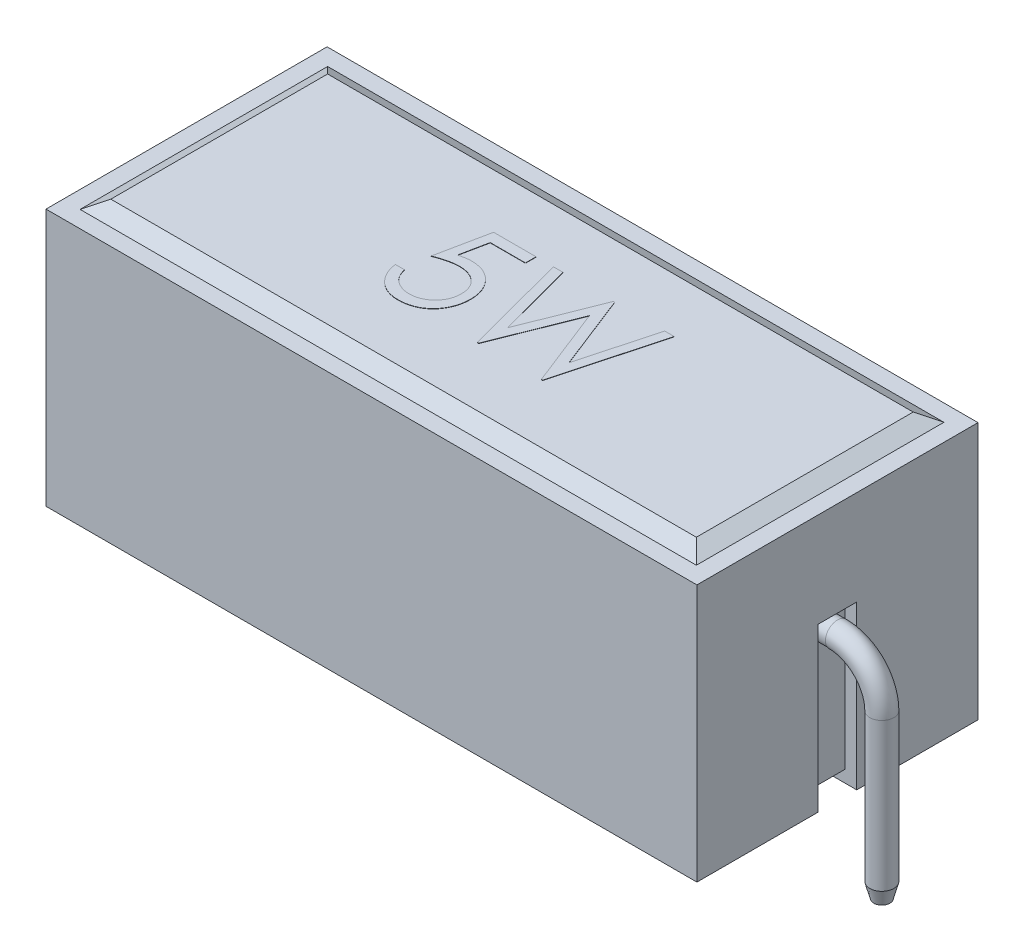
from build123d import *

# Parameters (mm, degrees)
SKETCH1_W            = 22
SKETCH1_H            = 9.5
BOSS_EXTRUDE1_DEPTH  = 8.7
SKETCH2_W            = 20.829563068
SKETCH2_H            = 8.366808904
BOSS_EXTRUDE2_DEPTH  = 0.3
BOSS_EXTRUDE2_TAPER  = 60
CUT_EXTRUDE1_DEPTH   = 0.4
CUT_EXTRUDE2_DEPTH   = 0.4
SKETCH5_W            = 1.3
SKETCH5_H            = 5.5
CUT_EXTRUDE4_DEPTH   = 0.4
SKETCH6_R            = 0.4
BOSS_EXTRUDE3_DEPTH  = 0.4
SKETCH7_R            = 0.4
BOSS_EXTRUDE4_DEPTH  = 0.4
SKETCH11_R           = 0.407100773
SKETCH14_R           = 0.407100773
BOSS_EXTRUDE6_DEPTH  = 5
SKETCH15_R           = 0.4
SKETCH17_R           = 0.4
BOSS_EXTRUDE7_DEPTH  = 5
SKETCH18_R           = 0.407100773
BOSS_EXTRUDE8_DEPTH  = 0.5
BOSS_EXTRUDE8_TAPER  = 15
SKETCH19_R           = 0.4
BOSS_EXTRUDE9_DEPTH  = 0.5
BOSS_EXTRUDE9_TAPER  = 15
BOSS_EXTRUDE10_DEPTH = 0.01


with BuildPart() as part:
    # Sketch1 → Boss-Extrude1 (new body)
    with BuildSketch(Plane(origin=(0, 0, 0), x_dir=(1, 0, 0), z_dir=(0, 1, 0))):
        Rectangle(SKETCH1_W, SKETCH1_H)
    extrude(amount=BOSS_EXTRUDE1_DEPTH)

    # Sketch3 → Cut-Extrude1 (cut)
    with BuildSketch(Plane(origin=(0, 0, 0), x_dir=(-1, 0, 0), z_dir=(0, -1, 0))):
        Polygon((11, -0.65), (9.9, -0.65), (8.5, -2.8), (-8.5, -2.8), (-9.9, -0.65), (-11, -0.65), (-11, 0.65), (-9.9, 0.65), (-8.5, 2.8), (8.5, 2.8), (9.9, 0.65), (11, 0.65), align=None)
    extrude(amount=-CUT_EXTRUDE1_DEPTH, mode=Mode.SUBTRACT)

    # Sketch4 → Cut-Extrude2 (cut)
    with BuildSketch(Plane(origin=(11, 0, 0), x_dir=(0, 0, -1), z_dir=(1, 0, 0))):
        Polygon((0, 0), (0.65, 0), (0.65, 5.5), (-0.65, 5.5), (-0.65, 0), align=None)
    extrude(amount=-CUT_EXTRUDE2_DEPTH, mode=Mode.SUBTRACT)

    # Sketch5 → Cut-Extrude4 (cut)
    with BuildSketch(Plane.ZY.offset(11)):
        with Locations((0, 2.75)):
            Rectangle(SKETCH5_W, SKETCH5_H)
    extrude(amount=-CUT_EXTRUDE4_DEPTH, mode=Mode.SUBTRACT)

    # Sketch6 → Boss-Extrude3 (add)
    with BuildSketch(Plane(origin=(10.6, 0, 0), x_dir=(0, 0, -1), z_dir=(1, 0, 0))):
        with Locations((0, 4.9)):
            Circle(SKETCH6_R)
    extrude(amount=BOSS_EXTRUDE3_DEPTH)

    # Sketch7 → Boss-Extrude4 (add)
    with BuildSketch(Plane.ZY.offset(10.6)):
        with Locations((0, 4.9)):
            Circle(SKETCH7_R)
    extrude(amount=BOSS_EXTRUDE4_DEPTH)

    # Sweep1: sweep along a path in Sketch13
    with BuildLine(Plane.XY) as sweep1_path:
        ThreePointArc((11, 4.892899227), (12.060644746, 4.453574824), (12.499999999, 3.392942857))
    # Sketch11 → Sweep1 (sweep)
    with BuildSketch(Plane(origin=(11, 0, 0), x_dir=(0, 0, -1), z_dir=(1, 0, 0))):
        with Locations((0, 4.892899227)):
            Circle(SKETCH11_R)
    sweep(path=sweep1_path.line)

    # Sketch14 → Boss-Extrude6 (add)
    with BuildSketch(Plane(origin=(-9.868e-05, 3.392579268, 0), x_dir=(1, 2.9087e-05, 0), z_dir=(2.9087e-05, -1, 0))):
        with Locations((12.500098684, 0)):
            Circle(SKETCH14_R)
    extrude(amount=BOSS_EXTRUDE6_DEPTH)

    # Sweep2: sweep along a path in Sketch16
    with BuildLine(Plane.XY) as sweep2_path:
        ThreePointArc((-12.499999995, 3.399877229), (-12.060703577, 4.460616765), (-11, 4.9))
    # Sketch15 → Sweep2 (sweep)
    with BuildSketch(Plane.ZY.offset(11)):
        with Locations((0, 4.9)):
            Circle(SKETCH15_R)
    sweep(path=sweep2_path.line)

    # Sketch17 → Boss-Extrude7 (add)
    with BuildSketch(Plane(origin=(-0.000278355, 3.400900299, 0), x_dir=(0.999999997, 8.1847e-05, 0), z_dir=(8.1847e-05, -0.999999997, 0))):
        with Locations((-12.499721682, 0)):
            Circle(SKETCH17_R)
    extrude(amount=BOSS_EXTRUDE7_DEPTH)

    # Sketch18 → Boss-Extrude8 (add)
    with BuildSketch(Plane(origin=(4.6755e-05, -1.60742073, 0), x_dir=(1, 2.9087e-05, 0), z_dir=(2.9087e-05, -1, 0))):
        with Locations((12.500098684, 0)):
            Circle(SKETCH18_R)
    extrude(amount=BOSS_EXTRUDE8_DEPTH, taper=BOSS_EXTRUDE8_TAPER)

    # Sketch19 → Boss-Extrude9 (add)
    with BuildSketch(Plane(origin=(0.000130882, -1.599099684, 0), x_dir=(0.999999997, 8.1847e-05, 0), z_dir=(8.1847e-05, -0.999999997, 0))):
        with Locations((-12.499721682, 0)):
            Circle(SKETCH19_R)
    extrude(amount=BOSS_EXTRUDE9_DEPTH, taper=BOSS_EXTRUDE9_TAPER)


with BuildPart() as body_2:
    # Sketch2 → Boss-Extrude2 (new body)
    with BuildSketch(Plane(origin=(0, 8.7, 0), x_dir=(1, 0, 0), z_dir=(0, 1, 0))):
        Rectangle(SKETCH2_W, SKETCH2_H)
    extrude(amount=BOSS_EXTRUDE2_DEPTH, taper=BOSS_EXTRUDE2_TAPER)

    # Sketch20 → Boss-Extrude10 (add)
    with BuildSketch(Plane(origin=(0, 9, 0), x_dir=(1, 0, 0), z_dir=(0, 1, 0))):
        with BuildLine():
            Line((-1.01173536, 1.825977974), (-1.01173536, 1.467003615))
            Line((-1.01173536, 1.467003615), (-2.202240168, 1.467003615))
            Line((-2.202240168, 1.467003615), (-2.390841931, 0.546430699))
            add(Edge.make_bspline(
                [(-2.390841931, 0.546430699), (-2.353786056, 0.556660971), (-2.281996161, 0.576480504), (-2.1760363, 0.598486275), (-2.075444096, 0.611751719), (-2.010168726, 0.613563029), (-1.978582315, 0.614439513)],
                knots=[0, 0, 0, 0, 0.000115302, 0.000223379, 0.000324431, 0.000419176, 0.000419176, 0.000419176, 0.000419176], degree=3))
            add(Edge.make_bspline(
                [(-1.978582315, 0.614439513), (-1.939498576, 0.613593577), (-1.862650178, 0.611930256), (-1.750211231, 0.595958407), (-1.642878338, 0.570818492), (-1.540875968, 0.53569797), (-1.444015417, 0.490788237), (-1.353187856, 0.434688297), (-1.267029943, 0.369154966), (-1.187087349, 0.293809954), (-1.114563041, 0.210888337), (-1.050797051, 0.121730466), (-0.996634461, 0.027202804), (-0.953073706, -0.073597805), (-0.918289372, -0.179556958), (-0.895137377, -0.291789541), (-0.879720668, -0.409237661), (-0.877998282, -0.489542231), (-0.877119976, -0.530492378)],
                knots=[0, 0, 0, 0, 0.00011719, 0.000230425, 0.000339944, 0.000447481, 0.000553499, 0.000659556, 0.000767111, 0.000877722, 0.000988528, 0.001097091, 0.001206056, 0.001314692, 0.001425996, 0.001539995, 0.001658004, 0.001780798, 0.001780798, 0.001780798, 0.001780798], degree=3))
            add(Edge.make_bspline(
                [(-0.877119976, -0.530492378), (-0.877785051, -0.559014599), (-0.879106214, -0.615673586), (-0.885824801, -0.699817787), (-0.898760517, -0.78218062), (-0.916128241, -0.862773012), (-0.938670659, -0.941442384), (-0.965959713, -1.018413912), (-0.999355741, -1.093208519), (-1.035987116, -1.166533914), (-1.077233594, -1.236732421), (-1.123012101, -1.302381407), (-1.171377593, -1.364465689), (-1.223418978, -1.422319422), (-1.279619973, -1.47556244), (-1.33929994, -1.524510721), (-1.401982659, -1.569992051), (-1.468637901, -1.610160247), (-1.537780384, -1.647123203), (-1.610408602, -1.67744674), (-1.684869302, -1.704557268), (-1.762234178, -1.726166796), (-1.84232799, -1.74309935), (-1.925282766, -1.754599951), (-2.010663436, -1.762976388), (-2.068538448, -1.763500745), (-2.097773021, -1.763765615)],
                knots=[0, 0, 0, 0, 8.5583e-05, 0.000170009, 0.000253005, 0.000335518, 0.000417186, 0.000498352, 0.000580291, 0.000662755, 0.000744161, 0.000824288, 0.000902692, 0.000980133, 0.001057498, 0.001134702, 0.00121156, 0.001289599, 0.001368002, 0.001446531, 0.001525481, 0.001605609, 0.001687289, 0.001770875, 0.001856759, 0.001944425, 0.001944425, 0.001944425, 0.001944425], degree=3))
            add(Edge.make_bspline(
                [(-2.097773021, -1.763765615), (-2.132647201, -1.763074777), (-2.201258032, -1.761715635), (-2.301778599, -1.74749715), (-2.398493205, -1.727133234), (-2.490623306, -1.696496964), (-2.57899457, -1.658109669), (-2.662417287, -1.609593498), (-2.743023063, -1.554614394), (-2.8175351, -1.489734041), (-2.886691214, -1.418818359), (-2.948597723, -1.341860718), (-3.003731299, -1.260131276), (-3.051209046, -1.173233121), (-3.091707068, -1.081394591), (-3.123522056, -0.98427159), (-3.149200411, -0.882371586), (-3.160063831, -0.812218075), (-3.165581514, -0.776586128)],
                knots=[0, 0, 0, 0, 0.000104552, 0.000205693, 0.000304023, 0.000400691, 0.00049644, 0.000592535, 0.000689779, 0.000788716, 0.000888377, 0.000986596, 0.001084603, 0.001183757, 0.001283279, 0.001385267, 0.001490017, 0.001598135, 0.001598135, 0.001598135, 0.001598135], degree=3))
            Line((-3.165581514, -0.776586128), (-2.85147895, -0.776586128))
            add(Edge.make_bspline(
                [(-2.85147895, -0.776586128), (-2.843750393, -0.809962581), (-2.828895676, -0.874113975), (-2.796289927, -0.964245317), (-2.756424052, -1.04456454), (-2.709019704, -1.116134124), (-2.652469673, -1.178543121), (-2.587940244, -1.234160183), (-2.515592521, -1.284335312), (-2.435199291, -1.326158079), (-2.350386212, -1.361826833), (-2.261619002, -1.385578528), (-2.171314656, -1.402279421), (-2.110236285, -1.403951181), (-2.079543854, -1.404791256)],
                knots=[0, 0, 0, 0, 0.000102709, 0.000197412, 0.000286774, 0.000371169, 0.000454082, 0.000538572, 0.000626283, 0.000717552, 0.000809994, 0.00090168, 0.00099274, 0.001084718, 0.001084718, 0.001084718, 0.001084718], degree=3))
            add(Edge.make_bspline(
                [(-2.079543854, -1.404791256), (-2.049585409, -1.403970478), (-1.990596987, -1.40235436), (-1.903785601, -1.389915348), (-1.819972726, -1.370757777), (-1.73998537, -1.342087922), (-1.66242383, -1.307243203), (-1.58925006, -1.262528127), (-1.518347182, -1.211068109), (-1.451919049, -1.152111479), (-1.3910796, -1.087141784), (-1.337323479, -1.017664391), (-1.292546565, -0.943547544), (-1.254812456, -0.866074391), (-1.226159157, -0.784395834), (-1.205718176, -0.698894659), (-1.193715117, -0.609359679), (-1.192063937, -0.548290369), (-1.19122254, -0.517171064)],
                knots=[0, 0, 0, 0, 8.9842e-05, 0.0001769, 0.000262612, 0.000347317, 0.000431396, 0.000517249, 0.000604055, 0.000693954, 0.000783242, 0.000870748, 0.000956963, 0.001042571, 0.001128832, 0.00121607, 0.001305907, 0.001399251, 0.001399251, 0.001399251, 0.001399251], degree=3))
            add(Edge.make_bspline(
                [(-1.19122254, -0.517171064), (-1.191881019, -0.489095312), (-1.193169899, -0.434141023), (-1.203700469, -0.353741817), (-1.222017442, -0.277668775), (-1.247441322, -0.205554541), (-1.279720829, -0.137331098), (-1.319167142, -0.072928038), (-1.36652054, -0.013194205), (-1.420612428, 0.041898349), (-1.479870469, 0.092743224), (-1.545314212, 0.13608731), (-1.615574139, 0.172551228), (-1.689803738, 0.204019226), (-1.769768637, 0.226619971), (-1.853885269, 0.243587857), (-1.943061977, 0.25340322), (-2.004032665, 0.254765108), (-2.035373181, 0.255465154)],
                knots=[0, 0, 0, 0, 8.4208e-05, 0.000164824, 0.000242709, 0.000318547, 0.000393815, 0.000468731, 0.000544614, 0.00062196, 0.000700062, 0.000778428, 0.000856831, 0.000937299, 0.001019835, 0.001105635, 0.00119452, 0.001288536, 0.001288536, 0.001288536, 0.001288536], degree=3))
            add(Edge.make_bspline(
                [(-2.035373181, 0.255465154), (-2.06250211, 0.254884563), (-2.118516465, 0.253685789), (-2.204439292, 0.244859292), (-2.294731015, 0.230619998), (-2.38904551, 0.211033751), (-2.487666018, 0.185402674), (-2.590384419, 0.154688173), (-2.697416686, 0.117966174), (-2.76953441, 0.090233961), (-2.806607155, 0.075977974)],
                knots=[0, 0, 0, 0, 8.1378e-05, 0.000168026, 0.000258858, 0.000355524, 0.000456875, 0.000564457, 0.000677092, 0.000796243, 0.000796243, 0.000796243, 0.000796243], degree=3))
            Line((-2.806607155, 0.075977974), (-2.447632796, 1.825977974))
            Line((-2.447632796, 1.825977974), (-1.01173536, 1.825977974))
        make_face()
        Polygon((-0.428402027, 1.825977974), (-0.103782636, 1.825977974), (0.581213358, -0.740828917), (1.599943326, 1.825977974), (1.645516242, 1.825977974), (2.645315922, -0.723300872), (3.333817524, 1.825977974), (3.654931306, 1.825977974), (2.71122137, -1.674022026), (2.666349576, -1.674022026), (1.61326464, 1.002860987), (0.547559511, -1.674022026), (0.502687717, -1.674022026), align=None)
    extrude(amount=BOSS_EXTRUDE10_DEPTH)


solid = Compound([part.part, body_2.part])
